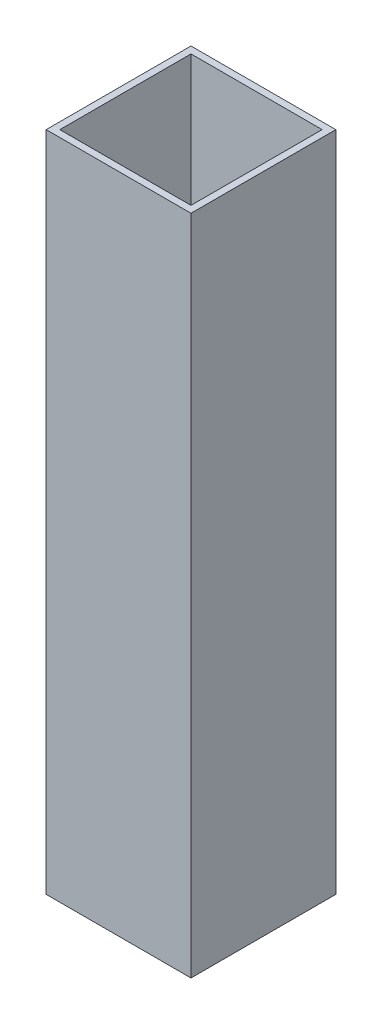
from build123d import *

# Parameters (mm, degrees)
SKETCH1_W           = 25.4
SKETCH1_H           = 25.4
SKETCH1_W_2         = 23
SKETCH1_H_2         = 23
BOSS_EXTRUDE1_DEPTH = 116.14


with BuildPart() as part:
    # Sketch1 → Boss-Extrude1 (new body)
    with BuildSketch(Plane(origin=(0, 0, 0), x_dir=(1, 0, 0), z_dir=(0, 1, 0))):
        with Locations((12.7, 12.7)):
            Rectangle(SKETCH1_W, SKETCH1_H)
        with Locations((12.7, 12.7)):
            Rectangle(SKETCH1_W_2, SKETCH1_H_2, mode=Mode.SUBTRACT)
    extrude(amount=BOSS_EXTRUDE1_DEPTH)


solid = part.part
